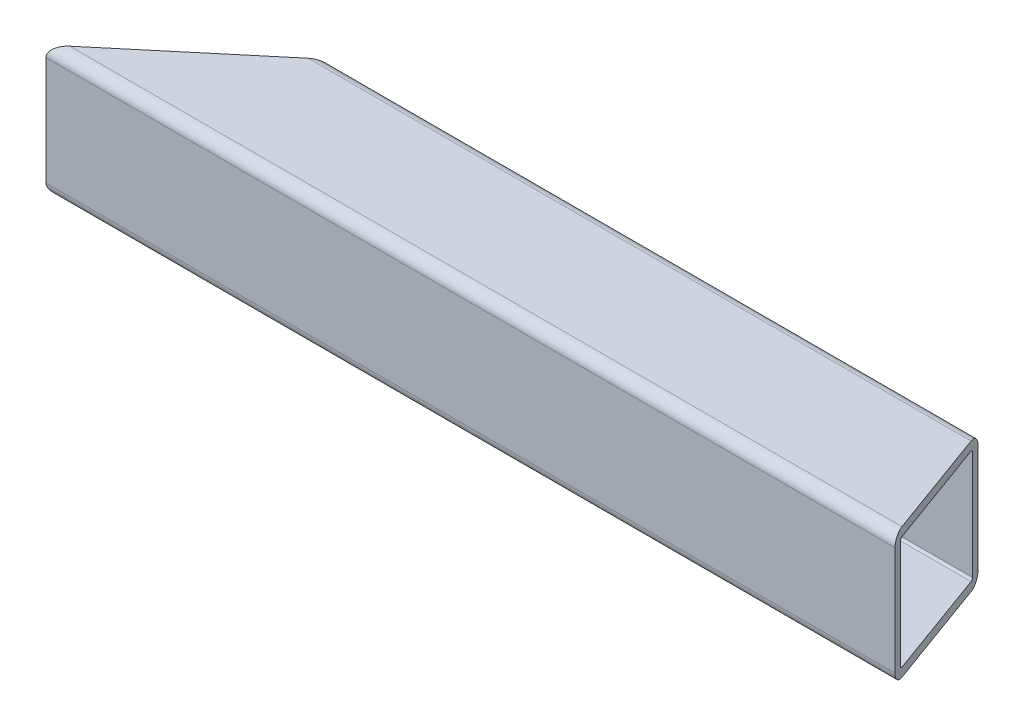
from build123d import *

# Parameters (mm, degrees)
EXTRUDE_THIN1_DEPTH     = 123.98756
CUT_EXTRUDE1_DEPTH      = 1
CUT_EXTRUDE1_DEPTH_BACK = 39.1
CUT_EXTRUDE2_DEPTH      = 1
CUT_EXTRUDE2_DEPTH_BACK = 39.1


with BuildPart() as part:
    # Sketch1 → Extrude-Thin1 (new body, symmetric)
    with BuildSketch(Plane(origin=(0, 0, 0), x_dir=(0, 0, -1), z_dir=(1, 0, 0))):
        with BuildLine():
            Line((-15.875, 19.05), (15.875, 19.05))
            ThreePointArc((15.875, 19.05), (18.12006403, 18.12006403), (19.05, 15.875))
            Line((19.05, 15.875), (19.05, -15.875))
            ThreePointArc((19.05, -15.875), (18.12006403, -18.12006403), (15.875, -19.05))
            Line((15.875, -19.05), (-15.875, -19.05))
            ThreePointArc((-15.875, -19.05), (-18.12006403, -18.12006403), (-19.05, -15.875))
            Line((-19.05, -15.875), (-19.05, 15.875))
            ThreePointArc((-19.05, 15.875), (-18.12006403, 18.12006403), (-15.875, 19.05))
        make_face()
        with BuildLine():
            Line((-15.875, 16.51), (15.875, 16.51))
            ThreePointArc((15.875, 16.51), (16.324012806, 16.324012806), (16.51, 15.875))
            Line((16.51, 15.875), (16.51, -15.875))
            ThreePointArc((16.51, -15.875), (16.324012806, -16.324012806), (15.875, -16.51))
            Line((15.875, -16.51), (-15.875, -16.51))
            ThreePointArc((-15.875, -16.51), (-16.324012806, -16.324012806), (-16.51, -15.875))
            Line((-16.51, -15.875), (-16.51, 15.875))
            ThreePointArc((-16.51, 15.875), (-16.324012806, 16.324012806), (-15.875, 16.51))
        make_face(mode=Mode.SUBTRACT)
    extrude(amount=EXTRUDE_THIN1_DEPTH, both=True)

    # Sketch3 → Cut-Extrude1 (cut, two sides)
    with BuildSketch(Plane(origin=(0, 19.05, 0), x_dir=(1, 0, 0), z_dir=(0, 1, 0))) as cut_extrude1_sk:
        Polygon((299.02319091, -499.956443526), (123.98756, -19.05), (110.120294074, 19.05), (-64.915336836, 499.956443526), (896.897550216, 850.027705346), (1260.836077962, -149.885181705), align=None)
    extrude(amount=CUT_EXTRUDE1_DEPTH, mode=Mode.SUBTRACT)
    extrude(cut_extrude1_sk.sketch, amount=-CUT_EXTRUDE1_DEPTH_BACK, mode=Mode.SUBTRACT)

    # Sketch4 → Cut-Extrude2 (cut, two sides)
    with BuildSketch(Plane(origin=(0, 19.05, 0), x_dir=(1, 0, 0), z_dir=(0, 1, 0))) as cut_extrude2_sk:
        Polygon((-516.026084699, -348.009381482), (-123.98756, -19.05), (-78.581748122, 19.05), (313.456776576, 348.009381482), (-344.461986387, 1132.086430879), (-1173.944847663, 436.067667915), align=None)
    extrude(amount=CUT_EXTRUDE2_DEPTH, mode=Mode.SUBTRACT)
    extrude(cut_extrude2_sk.sketch, amount=-CUT_EXTRUDE2_DEPTH_BACK, mode=Mode.SUBTRACT)


solid = part.part
